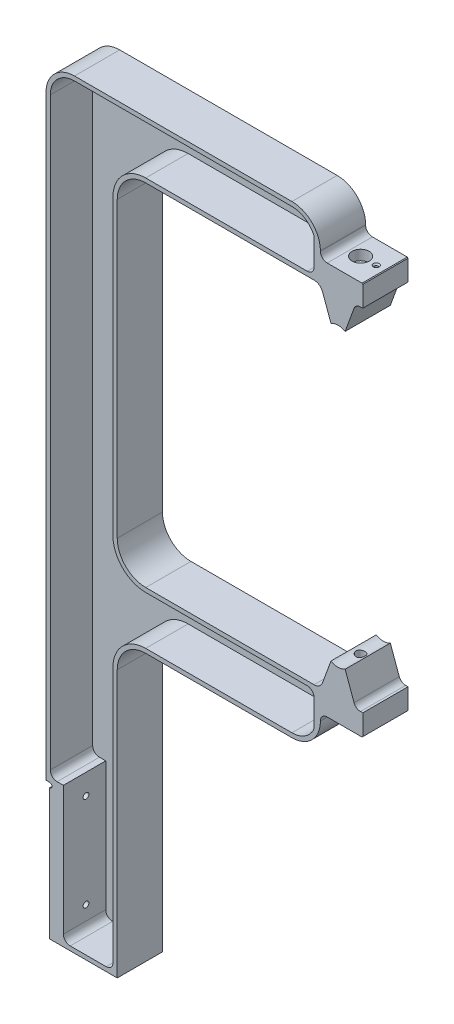
from build123d import *

# Parameters (mm, degrees)
BOSS_EXTRUDE1_DEPTH              = 15.875
SKETCH13_W                       = 2.54
SKETCH13_H                       = 95.25
CUT_EXTRUDE2_DEPTH               = 32.75
SKETCH14_W                       = 1.6002
SKETCH14_H                       = 3.302
CUT_EXTRUDE3_DEPTH               = 32.75
FILLET4_R                        = 1.5875
FILLET1_R                        = 6.35
FILLET2_R                        = 20
FILLET3_R                        = 4.7625
SKETCH10_R                       = 6
CUT_EXTRUDE1_DEPTH               = 7
F_4_40_TAPPED_HOLE1_D            = 2.2606
F_4_40_TAPPED_HOLE1_DEPTH        = 7.6
F_4_40_TAPPED_HOLE1_CSINK_D      = 4.1148
F_4_40_TAPPED_HOLE1_CSINK_ANGLE  = 90
F_4_40_TAPPED_HOLE1_TIP          = 0.679152758
CHAMFER1_SIZE                    = 0.5
F_10_32_TAPPED_HOLE1_D           = 4.0386
F_10_32_TAPPED_HOLE1_DEPTH       = 12.03
F_10_32_TAPPED_HOLE1_CSINK_D     = 6.096
F_10_32_TAPPED_HOLE1_CSINK_ANGLE = 90
F_10_32_TAPPED_HOLE1_TIP         = 1.213317848
CUT_EXTRUDE7_DEPTH               = 29.75
FILLET5_R                        = 4.7625


with BuildPart() as part:
    # Sketch1 → Boss-Extrude1 (new body, symmetric)
    with BuildSketch(Plane.XY):
        with BuildLine():
            Line((-313, -123), (-176.364963641, -123))
            Line((-176.364963641, -123), (-170.374987965, -123))
            Line((-170.374987965, -123), (-162.97678843, -102.673613833))
            ThreePointArc((-162.97678843, -102.673613833), (-158, -104), (-153.02321157, -102.673613833))
            Line((-153.02321157, -102.673613833), (-145.625012035, -123))
            Line((-145.625012035, -123), (-140.625012035, -123))
            Line((-140.625012035, -123), (-140.625012035, -138))
            Line((-140.625012035, -138), (-145.625012035, -138))
            Line((-145.625012035, -138), (-170.374987965, -138))
            Line((-170.374987965, -138), (-170.374987965, -163))
            Line((-170.374987965, -163), (-313, -163))
            Line((-313, -163), (-313, -370.4))
            Line((-313, -370.4), (-363, -370.4))
            Line((-363, -370.4), (-363, -163))
            Line((-363, -163), (-363, 163))
            Line((-363, 163), (-170.374987965, 163))
            Line((-170.374987965, 163), (-170.374987965, 138))
            Line((-170.374987965, 138), (-145.625012035, 138))
            Line((-145.625012035, 138), (-140.625012035, 138))
            Line((-140.625012035, 138), (-140.625012035, 123))
            Line((-140.625012035, 123), (-145.625012035, 123))
            Line((-145.625012035, 123), (-153.02321157, 102.673613833))
            ThreePointArc((-153.02321157, 102.673613833), (-158, 104), (-162.97678843, 102.673613833))
            Line((-162.97678843, 102.673613833), (-170.374987965, 123))
            Line((-170.374987965, 123), (-176.364963641, 123))
            Line((-176.364963641, 123), (-313, 123))
            Line((-313, 123), (-313, -123))
        make_face()
    extrude(amount=BOSS_EXTRUDE1_DEPTH, both=True)

    # Sketch13 → Cut-Extrude2 (cut, through all)
    with BuildSketch(Plane.XY.offset(15.875)):
        with Locations((-361.73, -322.775)):
            Rectangle(SKETCH13_W, SKETCH13_H)
    extrude(amount=-CUT_EXTRUDE2_DEPTH, mode=Mode.SUBTRACT)

    # Sketch14 → Cut-Extrude3 (cut, through all)
    with BuildSketch(Plane.XY.offset(15.875)):
        with Locations((-359.6599, -276.801)):
            Rectangle(SKETCH14_W, SKETCH14_H)
    extrude(amount=-CUT_EXTRUDE3_DEPTH, mode=Mode.SUBTRACT)

    # Fillet4
    fillet4_edges = [part.edges().sort_by_distance(p)[0] for p in [
        (-358.8598, -275.15, 0),
        (-358.8598, -278.452, 0),
    ]]
    fillet(fillet4_edges, radius=FILLET4_R)

    # Fillet1
    fillet1_edges = [part.edges().sort_by_distance(p)[0] for p in [
        (-170.374987965, -123, 0),
        (-170.374987965, 123, 0),
    ]]
    fillet(fillet1_edges, radius=FILLET1_R)

    # Fillet2
    fillet2_edges = [part.edges().sort_by_distance(p)[0] for p in [
        (-313, 123, 0),
        (-313, -123, 0),
        (-170.374987965, -163, 0),
        (-313, -163, 0),
        (-363, 163, 0),
        (-170.374987965, 163, 0),
    ]]
    fillet(fillet2_edges, radius=FILLET2_R)

    # Fillet3
    fillet3_edges = [part.edges().sort_by_distance(p)[0] for p in [
        (-145.625012035, -123, 0),
        (-170.374987965, -138, 0),
        (-170.374987965, 138, 0),
        (-145.625012035, 123, 0),
    ]]
    fillet(fillet3_edges, radius=FILLET3_R)

    # Sketch8 → M6 Clearance Hole1 (revolve, cut)
    with BuildSketch(Plane(origin=(-158, 138, 0), x_dir=(0, 0, 1), z_dir=(1, 0, 0))):
        Polygon((0, 0), (0, 51.960753981), (3.2, 50.038), (3.2, 0), align=None)
    m6_clearance_hole1 = revolve(axis=Axis((-158, 144.35, 0), (0, -1, 0)), mode=Mode.SUBTRACT)

    # Sketch10 → Cut-Extrude1 (cut)
    with BuildSketch(Plane(origin=(0, 138, 0), x_dir=(1, 0, 0), z_dir=(0, 1, 0))):
        with Locations(Location((-158, 0, 0), (0, 0, 270))):  # turned: the seam where the file's is
            Circle(SKETCH10_R)
    extrude(amount=-CUT_EXTRUDE1_DEPTH, mode=Mode.SUBTRACT)

    # #4-40 Tapped Hole1
    with Locations(Plane(origin=(0, 138, 0), x_dir=(-1, 0, 0), z_dir=(0, 1, 0))):
        with Locations((147, 0)):
            CounterSinkHole(F_4_40_TAPPED_HOLE1_D / 2, F_4_40_TAPPED_HOLE1_CSINK_D / 2, depth=F_4_40_TAPPED_HOLE1_DEPTH, counter_sink_angle=F_4_40_TAPPED_HOLE1_CSINK_ANGLE)
            with Locations((0, 0, -(F_4_40_TAPPED_HOLE1_DEPTH + F_4_40_TAPPED_HOLE1_TIP / 2))):  # 118° drill point
                Cone(0, F_4_40_TAPPED_HOLE1_D / 2, F_4_40_TAPPED_HOLE1_TIP, mode=Mode.SUBTRACT)

    # Mirror1: M6 Clearance Hole1 across plane
    add(m6_clearance_hole1.mirror(Plane.ZX), mode=Mode.SUBTRACT)

    # Chamfer1
    chamfer1_edges = [part.edges().sort_by_distance(p)[0] for p in [
        (-140.625012035, -138, 0),
        (-140.625012035, 138, 0),
    ]]
    chamfer(chamfer1_edges, length=CHAMFER1_SIZE)

    # #10-32 Tapped Hole1
    with Locations(Plane.ZY.offset(360.46)):
        with Locations((0, -286.58), (0, -352.62)):
            CounterSinkHole(F_10_32_TAPPED_HOLE1_D / 2, F_10_32_TAPPED_HOLE1_CSINK_D / 2, depth=F_10_32_TAPPED_HOLE1_DEPTH, counter_sink_angle=F_10_32_TAPPED_HOLE1_CSINK_ANGLE)
            with Locations((0, 0, -(F_10_32_TAPPED_HOLE1_DEPTH + F_10_32_TAPPED_HOLE1_TIP / 2))):  # 118° drill point
                Cone(0, F_10_32_TAPPED_HOLE1_D / 2, F_10_32_TAPPED_HOLE1_TIP, mode=Mode.SUBTRACT)

    # Sketch25 → Cut-Extrude7 (cut)
    with BuildSketch(Plane.XY.offset(15.875)):
        with BuildLine():
            Line((-190.374987965, 160), (-343, 160))
            ThreePointArc((-343, 160), (-355.02081528, 155.02081528), (-360, 143))
            Line((-360, 143), (-360, -272.15))
            Line((-360, -272.15), (-350.808, -272.15))
            Line((-350.808, -272.15), (-350.808, -367.4))
            Line((-350.808, -367.4), (-316, -367.4))
            Line((-316, -367.4), (-316, -183))
            ThreePointArc((-316, -183), (-309.263455967, -166.736544033), (-293, -160))
            Line((-293, -160), (-190.374987965, -160))
            ThreePointArc((-190.374987965, -160), (-181.091910782, -157.241645903), (-174.821305833, -149.861703296))
            Line((-174.821305833, -149.861703296), (-174.821305833, -126))
            Line((-174.821305833, -126), (-293, -126))
            ThreePointArc((-293, -126), (-309.263455967, -119.263455967), (-316, -103))
            Line((-316, -103), (-316, 103))
            ThreePointArc((-316, 103), (-309.263455967, 119.263455967), (-293, 126))
            Line((-293, 126), (-174.821305833, 126))
            Line((-174.821305833, 126), (-174.821305833, 149.861703296))
            ThreePointArc((-174.821305833, 149.861703296), (-181.091910782, 157.241645903), (-190.374987965, 160))
        make_face()
    extrude(amount=-CUT_EXTRUDE7_DEPTH, mode=Mode.SUBTRACT)

    # Fillet5
    fillet5_edges = [part.edges().sort_by_distance(p)[0] for p in [
        (-350.808, -367.4, 1),
        (-316, -367.4, 1),
        (-174.821305833, -149.861703296, 1),
        (-174.821305833, -126, 1),
        (-174.821305833, 126, 1),
        (-174.821305833, 149.861703296, 1),
        (-360, -272.15, 1),
    ]]
    fillet(fillet5_edges, radius=FILLET5_R)


solid = part.part
